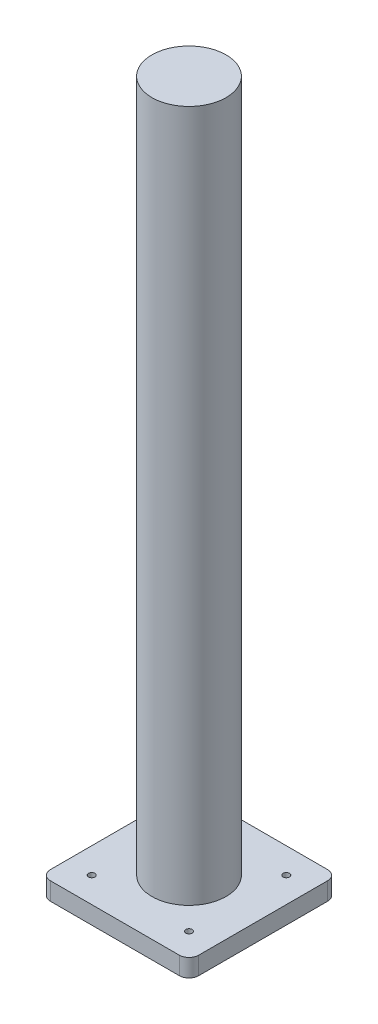
from build123d import *

# Parameters (mm, degrees)
SKETCH1_W           = 76.2
SKETCH1_H           = 76.2
BOSS_EXTRUDE1_DEPTH = 9.144
SKETCH2_R           = 1.65
CUT_EXTRUDE1_DEPTH  = 9.144
SKETCH3_R           = 19.05
BOSS_EXTRUDE2_DEPTH = 355.6
FILLET1_R           = 5


with BuildPart() as part:
    # Sketch1 → Boss-Extrude1 (new body)
    with BuildSketch(Plane(origin=(0, 0, 0), x_dir=(1, 0, 0), z_dir=(0, 1, 0))):
        with Locations((38.1, 38.1)):
            Rectangle(SKETCH1_W, SKETCH1_H)
    extrude(amount=BOSS_EXTRUDE1_DEPTH)

    # Sketch2 → Cut-Extrude1 (cut)
    with BuildSketch(Plane(origin=(0, 9.144, 0), x_dir=(1, 0, 0), z_dir=(0, 1, 0))):
        with Locations((13.1, 63.1)):
            Circle(SKETCH2_R)
        with Locations((63.1, 63.1)):
            Circle(SKETCH2_R)
        with Locations((63.1, 13.1)):
            Circle(SKETCH2_R)
        with Locations((13.1, 13.1)):
            Circle(SKETCH2_R)
    extrude(amount=-CUT_EXTRUDE1_DEPTH, mode=Mode.SUBTRACT)

    # Sketch3 → Boss-Extrude2 (add)
    with BuildSketch(Plane(origin=(0, 9.144, 0), x_dir=(1, 0, 0), z_dir=(0, 1, 0))):
        with Locations((38.1, 38.1)):
            Circle(SKETCH3_R)
    extrude(amount=BOSS_EXTRUDE2_DEPTH)

    # Fillet1
    fillet1_edges = [part.edges().sort_by_distance(p)[0] for p in [
        (0, 4.572, -76.2),
        (76.2, 4.572, -76.2),
        (76.2, 4.572, 0),
        (0, 4.572, 0),
    ]]
    fillet(fillet1_edges, radius=FILLET1_R)


solid = part.part
